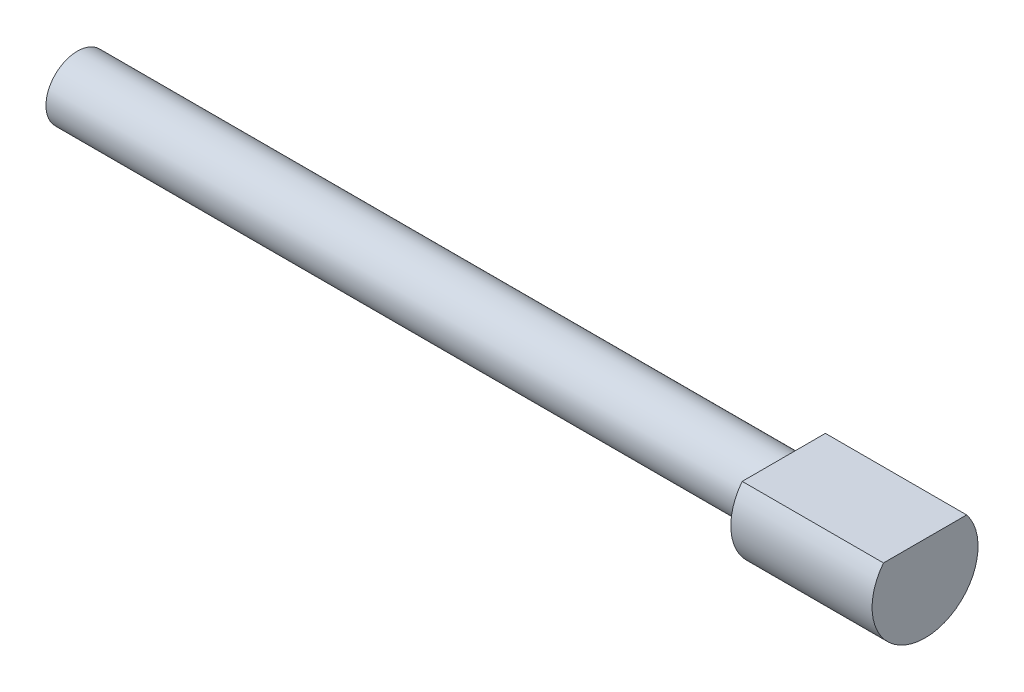
from build123d import *

# Parameters (mm, degrees)
SKETCH2_R           = 1.1303
BOSS_EXTRUDE1_DEPTH = 25.4
SKETCH3_R           = 1.905
BOSS_EXTRUDE2_DEPTH = 5.08
CUT_EXTRUDE1_DEPTH  = 5.08


with BuildPart() as part:
    # Sketch2 → Boss-Extrude1 (new body)
    with BuildSketch(Plane(origin=(0, 0, 0), x_dir=(0, 0, -1), z_dir=(1, 0, 0))):
        Circle(SKETCH2_R)
    extrude(amount=-BOSS_EXTRUDE1_DEPTH)

    # Sketch3 → Boss-Extrude2 (add)
    with BuildSketch(Plane(origin=(0, 0, 0), x_dir=(0, 0, -1), z_dir=(1, 0, 0))):
        Circle(SKETCH3_R)
    extrude(amount=BOSS_EXTRUDE2_DEPTH)

    # Sketch4 → Cut-Extrude1 (cut)
    with BuildSketch(Plane(origin=(5.08, 0, 0), x_dir=(0, 0, -1), z_dir=(1, 0, 0))):
        with BuildLine():
            Line((-1.495366573, 1.18021346), (1.495366573, 1.18021346))
            ThreePointArc((1.495366573, 1.18021346), (0, 1.905), (-1.495366573, 1.18021346))
        make_face()
    extrude(amount=-CUT_EXTRUDE1_DEPTH, mode=Mode.SUBTRACT)


solid = part.part
